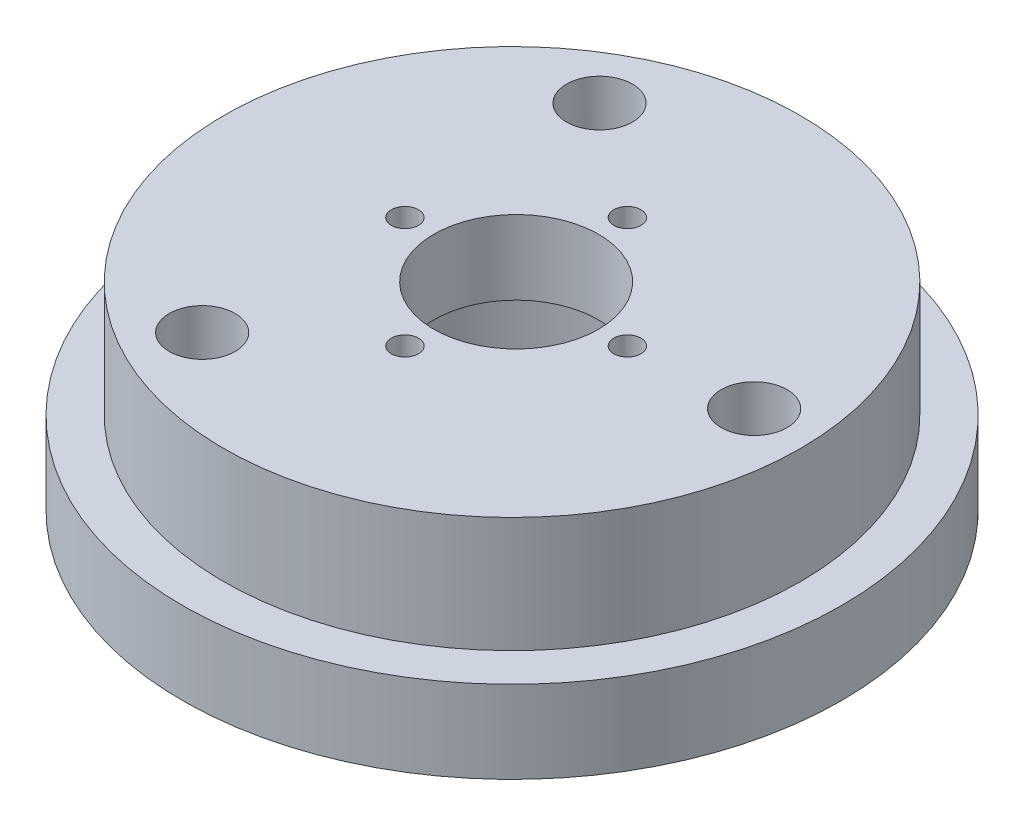
from build123d import *

# Parameters (mm, degrees)
CUT_EXTRUDE2_DEPTH      = 62.449165983
CUT_EXTRUDE2_DEPTH_BACK = 62.449165983
SKETCH2_R               = 10
SKETCH2_R_2             = 1.65
SKETCH2_5_R             = 20
SKETCH2_5_R_2           = 1.65
SKETCH2_5_R_3           = 10
CUT_EXTRUDE3_DEPTH      = 15
CUT_EXTRUDE4_DEPTH      = 62.449165983
CUT_EXTRUDE4_DEPTH_BACK = 62.449165983
SKETCH3_R               = 4


with BuildPart() as part:
    # Sketch1 → Revolve1 (revolve)
    with BuildSketch(Plane.XY):
        Polygon((-40, 10), (-35, 10), (-35, 24), (0, 24), (0, 0), (-40, 0), align=None)
    revolve(axis=Axis((0, -1000, 0), (0, 1, 0)))

    # Sketch2 → Cut-Extrude2 (cut, two sides: drawn at the far end of the back side and taken through both)
    with BuildSketch(Plane.XZ.offset(-CUT_EXTRUDE2_DEPTH_BACK)):
        with Locations((0.220332098, -0.275415123)):
            Circle(SKETCH2_R)
        with Locations((-13.279667902, -0.275415123)):
            Circle(SKETCH2_R_2)
        with Locations((13.720332098, -0.275415123)):
            Circle(SKETCH2_R_2)
        with Locations((0.220332098, 13.224584877)):
            Circle(SKETCH2_R_2)
        with Locations((0.220332098, -13.775415123)):
            Circle(SKETCH2_R_2)
    extrude(amount=CUT_EXTRUDE2_DEPTH + CUT_EXTRUDE2_DEPTH_BACK, mode=Mode.SUBTRACT)

    # Sketch2_5 → Cut-Extrude3 (cut)
    with BuildSketch(Plane.XZ):
        with Locations((0.220332098, -0.275415123)):
            Circle(SKETCH2_5_R)
        with Locations((0.220332098, -13.775415123)):
            Circle(SKETCH2_5_R_2, mode=Mode.SUBTRACT)
        with Locations((-13.279667902, -0.275415123)):
            Circle(SKETCH2_5_R_2, mode=Mode.SUBTRACT)
        with Locations((0.220332098, -0.275415123)):
            Circle(SKETCH2_5_R_3, mode=Mode.SUBTRACT)
        with Locations((13.720332098, -0.275415123)):
            Circle(SKETCH2_5_R_2, mode=Mode.SUBTRACT)
        with Locations((0.220332098, 13.224584877)):
            Circle(SKETCH2_5_R_2, mode=Mode.SUBTRACT)
    extrude(amount=-CUT_EXTRUDE3_DEPTH, mode=Mode.SUBTRACT)

    # Sketch3 → Cut-Extrude4 (cut, two sides: drawn at the far end of the back side and taken through both)
    with BuildSketch(Plane(origin=(0, 24, 0), x_dir=(1, 0, 0), z_dir=(0, 1, 0)).offset(-CUT_EXTRUDE4_DEPTH_BACK)):
        with Locations((28, 1.382050236)):
            Circle(SKETCH3_R)
        with Locations((-13.5, -24.11)):
            Circle(SKETCH3_R)
        with Locations((-13.5, 24.11473671)):
            Circle(SKETCH3_R)
    extrude(amount=CUT_EXTRUDE4_DEPTH + CUT_EXTRUDE4_DEPTH_BACK, mode=Mode.SUBTRACT)


solid = part.part
